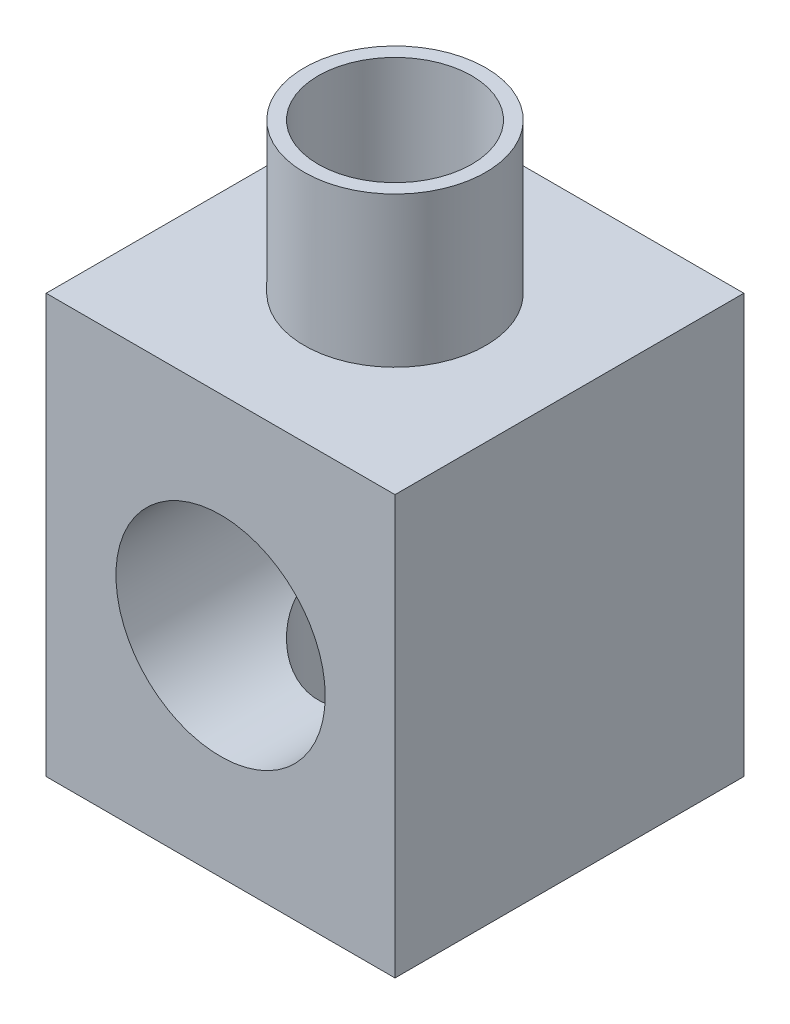
from build123d import *

# Parameters (mm, degrees)
CROQUIS1_W              = 50
CROQUIS1_H              = 50
CROQUIS1_R              = 11
SALIENTE_EXTRUIR1_DEPTH = 60
CROQUIS3_R              = 15
CORTAR_EXTRUIR1_DEPTH   = 47
CROQUIS4_R              = 4
CORTAR_EXTRUIR2_DEPTH   = 10
CROQUIS5_R              = 13
CROQUIS5_R_2            = 11
SALIENTE_EXTRUIR3_DEPTH = 21.5
CROQUIS7_R              = 13
CROQUIS7_R_2            = 11
SALIENTE_EXTRUIR4_DEPTH = 10


with BuildPart() as part:
    # Croquis1 → Saliente-Extruir1 (new body)
    with BuildSketch(Plane(origin=(0, 0, 0), x_dir=(1, 0, 0), z_dir=(0, 1, 0))):
        Rectangle(CROQUIS1_W, CROQUIS1_H)
        Circle(CROQUIS1_R, mode=Mode.SUBTRACT)
    extrude(amount=SALIENTE_EXTRUIR1_DEPTH)

    # Croquis3 → Cortar-Extruir1 (cut)
    with BuildSketch(Plane.XY.offset(25)):
        with Locations((0, 30)):
            Circle(CROQUIS3_R)
    extrude(amount=-CORTAR_EXTRUIR1_DEPTH, mode=Mode.SUBTRACT)

    # Croquis4 → Cortar-Extruir2 (cut)
    with BuildSketch(Plane.XY.offset(-22)):
        with Locations((0, 30)):
            Circle(CROQUIS4_R)
    extrude(amount=-CORTAR_EXTRUIR2_DEPTH, mode=Mode.SUBTRACT)

    # Croquis5 → Saliente-Extruir3 (add)
    with BuildSketch(Plane(origin=(0, 60, 0), x_dir=(1, 0, 0), z_dir=(0, 1, 0))):
        Circle(CROQUIS5_R)
        Circle(CROQUIS5_R_2, mode=Mode.SUBTRACT)
    extrude(amount=SALIENTE_EXTRUIR3_DEPTH)

    # Croquis7 → Saliente-Extruir4 (add)
    with BuildSketch(Plane.XZ):
        Circle(CROQUIS7_R)
        Circle(CROQUIS7_R_2, mode=Mode.SUBTRACT)
    extrude(amount=SALIENTE_EXTRUIR4_DEPTH)


solid = part.part
